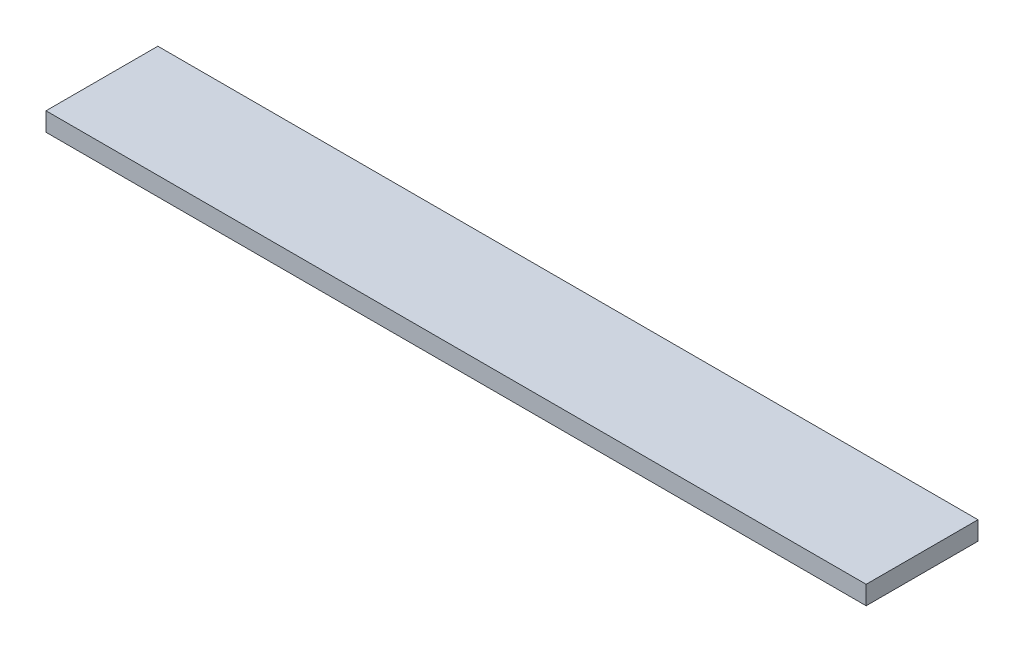
from build123d import *

# Parameters (mm, degrees)
SKETCH1_W           = 558.8
SKETCH1_H           = 76.2
BOSS_EXTRUDE1_DEPTH = 12.7


with BuildPart() as part:
    # Sketch1 → Boss-Extrude1 (new body)
    with BuildSketch(Plane(origin=(0, 0, 0), x_dir=(1, 0, 0), z_dir=(0, 1, 0))):
        with Locations((191.834474042, 2.936232023)):
            Rectangle(SKETCH1_W, SKETCH1_H)
    extrude(amount=BOSS_EXTRUDE1_DEPTH)


solid = part.part
